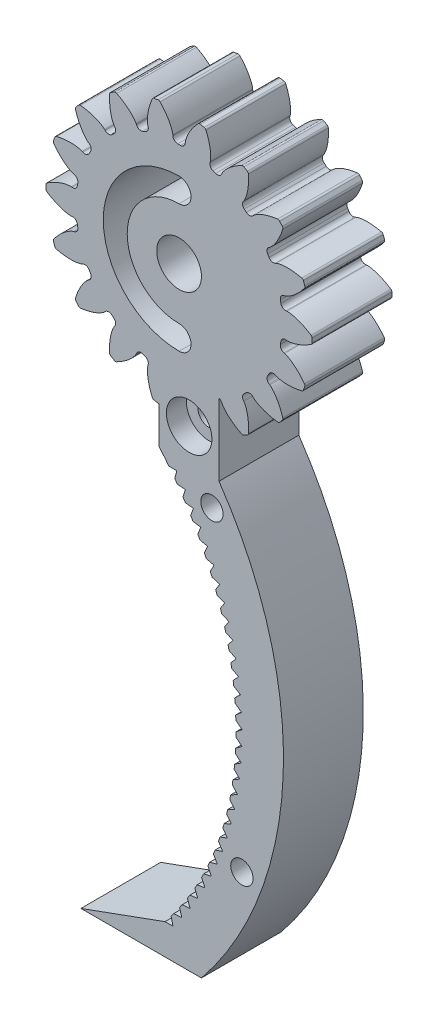
from build123d import *

# Parameters (mm, degrees)
SKETCH1_R                                 = 21.166666667
BOSS_EXTRUDE1_DEPTH                       = 12.7
CUT_EXTRUDE_DCLTBC_DEPTH                  = 13.7
FILLET_TIP_DCLTBC_R                       = 0.376401082
FILLET_ROOT_DCLTBC_R                      = 0.752802164
CIRPATTERN_DCLTBC_COUNT                   = 18
FILLET_TIP_DCLTBC_OF_CIRPATTERN_DCLTBC_R  = 0.376401082
FILLET_ROOT_DCLTBC_OF_CIRPATTERN_DCLTBC_R = 0.752802164
SKETCH4_R                                 = 3.556
CUT_EXTRUDE2_DEPTH                        = 13.7000001
BOSS_EXTRUDE3_DEPTH                       = 12.7
SKETCH9_R                                 = 1.778
CUT_EXTRUDE4_DEPTH                        = 101.6
CUT_EXTRUDE6_DEPTH                        = 13.7000001
CIRPATTERN1_COUNT                         = 30
CIRPATTERN1_ANGLE                         = 75
CUT_EXTRUDE7_DEPTH                        = 12.7
SKETCH13_R                                = 1.778
CUT_EXTRUDE8_DEPTH                        = 12.7
SKETCH14_R                                = 3.6195
CUT_EXTRUDE9_DEPTH                        = 3.175
SKETCH15_R                                = 3.6195
CUT_EXTRUDE10_DEPTH                       = 3.175


with BuildPart() as part:
    # Sketch1 → Boss-Extrude1 (new body)
    with BuildSketch(Plane.XY):
        Circle(SKETCH1_R)
    extrude(amount=BOSS_EXTRUDE1_DEPTH)

    # DCLTBC → Cut-Extrude-DCLTBC (cut, through all)
    with BuildSketch(Plane.XY):
        with BuildLine():
            Line((-0.988599485, 17.23683661), (-0.939299003, 16.37725256))
            ThreePointArc((-0.939299003, 16.37725256), (0, 16.404166667), (0.939299003, 16.37725256))
            Line((0.939299003, 16.37725256), (0.988599485, 17.23683661))
            add(Edge.make_bspline(
                [(0.988599485, 17.23683661), (0.989063314, 17.24324115), (0.990661792, 17.261181979), (0.994858273, 17.295004515), (1.003369641, 17.350013815), (1.016655031, 17.419804647), (1.036619493, 17.509601098), (1.063718234, 17.614795353), (1.097234262, 17.729707804), (1.137709634, 17.85389969), (1.181621422, 17.977005275), (1.228695452, 18.099012466), (1.278527467, 18.219794849), (1.342341331, 18.365146152), (1.42364652, 18.538069209), (1.525589195, 18.738036686), (1.649316002, 18.962165854), (1.783980218, 19.187521629), (1.923498112, 19.406676656), (2.072405817, 19.624910262), (2.222105415, 19.833784741), (2.385586794, 20.047220122), (2.540566559, 20.242458208), (2.722891612, 20.457068476), (2.872582231, 20.629074977), (3.034353491, 20.803165616), (3.114136758, 20.887359483), (3.155350355, 20.930158669)],
                knots=[0, 0, 0, 0, 0, 0.005376749, 0.015083688, 0.02853182, 0.04661014, 0.064854849, 0.092110525, 0.119476176, 0.146842496, 0.174208854, 0.201574956, 0.228941013, 0.256307345, 0.307035032, 0.361767352, 0.416499661, 0.471231937, 0.525964282, 0.580696616, 0.635428982, 0.690161387, 0.744893688, 0.799626082, 0.854358408, 0.909090915, 0.909090915, 0.909090915, 0.909090915, 0.909090915], degree=4))
            ThreePointArc((3.155350355, 20.930158669), (0, 21.166666667), (-3.155350355, 20.930158669))
            add(Edge.make_bspline(
                [(-0.988599485, 17.23683661), (-0.989063314, 17.24324115), (-0.990661792, 17.261181979), (-0.994858273, 17.295004515), (-1.003369641, 17.350013815), (-1.016655031, 17.419804647), (-1.036619493, 17.509601098), (-1.063718234, 17.614795353), (-1.097234262, 17.729707804), (-1.137709634, 17.85389969), (-1.181621422, 17.977005275), (-1.228695452, 18.099012466), (-1.278527467, 18.219794849), (-1.342341331, 18.365146152), (-1.42364652, 18.538069209), (-1.525589195, 18.738036686), (-1.649316002, 18.962165854), (-1.783980218, 19.187521629), (-1.923498112, 19.406676656), (-2.072405817, 19.624910262), (-2.222105415, 19.833784741), (-2.385586794, 20.047220122), (-2.540566559, 20.242458208), (-2.722891612, 20.457068476), (-2.872582231, 20.629074977), (-3.034353491, 20.803165616), (-3.114136758, 20.887359483), (-3.155350355, 20.930158669)],
                knots=[0, 0, 0, 0, 0, 0.005376749, 0.015083688, 0.02853182, 0.04661014, 0.064854849, 0.092110525, 0.119476176, 0.146842496, 0.174208854, 0.201574956, 0.228941013, 0.256307345, 0.307035032, 0.361767352, 0.416499661, 0.471231937, 0.525964282, 0.580696616, 0.635428982, 0.690161387, 0.744893688, 0.799626082, 0.854358408, 0.909090915, 0.909090915, 0.909090915, 0.909090915, 0.909090915], degree=4))
        make_face()
    cut_extrude_dcltbc = extrude(amount=CUT_EXTRUDE_DCLTBC_DEPTH, mode=Mode.SUBTRACT)

    # Fillet-Tip-DCLTBC
    fillet_tip_dcltbc_edges = [part.edges().sort_by_distance(p)[0] for p in [
        (3.155350355, 20.930158669, 6.35),
        (-3.155350355, 20.930158669, 6.35),
    ]]
    fillet(fillet_tip_dcltbc_edges, radius=FILLET_TIP_DCLTBC_R)

    # Fillet-Root-DCLTBC
    fillet_root_dcltbc_edges = [part.edges().sort_by_distance(p)[0] for p in [
        (0.939299003, 16.37725256, 6.35),
        (-0.939299003, 16.37725256, 6.35),
    ]]
    fillet(fillet_root_dcltbc_edges, radius=FILLET_ROOT_DCLTBC_R)

    # CirPattern-DCLTBC: Cut-Extrude-DCLTBC ×18 about axis
    cirpattern_dcltbc_axis = Axis((0, 0, 12.7), (0, 0, 1))
    for i in range(1, CIRPATTERN_DCLTBC_COUNT):
        add(cut_extrude_dcltbc.rotate(cirpattern_dcltbc_axis, i * 360 / CIRPATTERN_DCLTBC_COUNT), mode=Mode.SUBTRACT)

    # Fillet-Tip-DCLTBC of CirPattern-DCLTBC
    fillet_tip_dcltbc_of_cirpattern_dcltbc_edges = [part.edges().sort_by_distance(p)[0] for p in [
        (-4.193476424, 20.747109034, 6.35),
        (-10.123595312, 18.588722273, 6.35),
        (-11.036508056, 18.061651854, 6.35),
        (-15.870785267, 14.00521163, 6.35),
        (-16.548373935, 13.1976929, 6.35),
        (-19.70372429, 7.73246577, 6.35),
        (-20.06426169, 6.741897404, 6.35),
        (-21.160103368, 0.527070418, 6.35),
        (-21.160103368, -0.527070418, 6.35),
        (-20.06426169, -6.741897404, 6.35),
        (-19.70372429, -7.73246577, 6.35),
        (-16.548373935, -13.1976929, 6.35),
        (-15.870785267, -14.00521163, 6.35),
        (-11.036508056, -18.061651854, 6.35),
        (-10.123595312, -18.588722273, 6.35),
        (-4.193476424, -20.747109034, 6.35),
        (-3.155350355, -20.930158669, 6.35),
        (3.155350355, -20.930158669, 6.35),
        (4.193476424, -20.747109034, 6.35),
        (10.123595312, -18.588722273, 6.35),
        (11.036508056, -18.061651854, 6.35),
        (15.870785267, -14.00521163, 6.35),
        (16.548373935, -13.1976929, 6.35),
        (19.70372429, -7.73246577, 6.35),
        (20.06426169, -6.741897404, 6.35),
        (21.160103368, -0.527070418, 6.35),
        (21.160103368, 0.527070418, 6.35),
        (20.06426169, 6.741897404, 6.35),
        (19.70372429, 7.73246577, 6.35),
        (16.548373935, 13.1976929, 6.35),
        (15.870785267, 14.00521163, 6.35),
        (11.036508056, 18.061651854, 6.35),
        (10.123595312, 18.588722273, 6.35),
        (4.193476424, 20.747109034, 6.35),
    ]]
    fillet(fillet_tip_dcltbc_of_cirpattern_dcltbc_edges, radius=FILLET_TIP_DCLTBC_OF_CIRPATTERN_DCLTBC_R)

    # Fillet-Root-DCLTBC of CirPattern-DCLTBC
    fillet_root_dcltbc_of_cirpattern_dcltbc_edges = [part.edges().sort_by_distance(p)[0] for p in [
        (-4.718697926, 15.710842559, 6.35),
        (-6.48400261, 15.0683242, 6.35),
        (-9.807550244, 13.149473078, 6.35),
        (-11.246639808, 11.941933556, 6.35),
        (-13.71346726, 9.002083078, 6.35),
        (-14.652766263, 7.375169482, 6.35),
        (-15.965337734, 3.768909003, 6.35),
        (-16.291552854, 1.918851122, 6.35),
        (-16.291552854, -1.918851122, 6.35),
        (-15.965337734, -3.768909003, 6.35),
        (-14.652766263, -7.375169482, 6.35),
        (-13.71346726, -9.002083078, 6.35),
        (-11.246639808, -11.941933556, 6.35),
        (-9.807550244, -13.149473078, 6.35),
        (-6.48400261, -15.0683242, 6.35),
        (-4.718697926, -15.710842559, 6.35),
        (-0.939299003, -16.37725256, 6.35),
        (0.939299003, -16.37725256, 6.35),
        (4.718697926, -15.710842559, 6.35),
        (6.48400261, -15.0683242, 6.35),
        (9.807550244, -13.149473078, 6.35),
        (11.246639808, -11.941933556, 6.35),
        (13.71346726, -9.002083078, 6.35),
        (14.652766263, -7.375169482, 6.35),
        (15.965337734, -3.768909003, 6.35),
        (16.291552854, -1.918851122, 6.35),
        (16.291552854, 1.918851122, 6.35),
        (15.965337734, 3.768909003, 6.35),
        (14.652766263, 7.375169482, 6.35),
        (13.71346726, 9.002083078, 6.35),
        (11.246639808, 11.941933556, 6.35),
        (9.807550244, 13.149473078, 6.35),
        (6.48400261, 15.0683242, 6.35),
        (4.718697926, 15.710842559, 6.35),
    ]]
    fillet(fillet_root_dcltbc_of_cirpattern_dcltbc_edges, radius=FILLET_ROOT_DCLTBC_OF_CIRPATTERN_DCLTBC_R)

    # Sketch4 → Cut-Extrude2 (cut, through all)
    with BuildSketch(Plane.XY.offset(12.7)):
        Circle(SKETCH4_R)
    extrude(amount=-CUT_EXTRUDE2_DEPTH, mode=Mode.SUBTRACT)

    # Sketch7 → Boss-Extrude3 (add, through all)
    with BuildSketch(Plane.XY.offset(12.7)):
        with BuildLine():
            Line((6.35, -14.113720517), (6.35, -26.813720517))
            ThreePointArc((6.35, -26.813720517), (16.563553869, -62.204697552), (3.547653041, -96.663720517))
            Line((3.547653041, -96.663720517), (-15.629346959, -96.663720517))
            Line((-15.629346959, -96.663720517), (-2.2365023, -91.788432197))
            ThreePointArc((-2.2365023, -91.788432197), (9.041883703, -59.131392983), (-3.175, -26.813720517))
            Line((-3.175, -26.813720517), (-3.175, -14.113720517))
            Line((-3.175, -14.113720517), (6.35, -14.113720517))
        make_face()
    extrude(amount=-BOSS_EXTRUDE3_DEPTH)

    # Sketch9 → Cut-Extrude4 (cut)
    with BuildSketch(Plane.XY.offset(12.7)):
        with Locations((5.222816577, -31.033083261)):
            Circle(SKETCH9_R)
        with Locations((9.993601717, -78.846696124)):
            Circle(SKETCH9_R)
    extrude(amount=-CUT_EXTRUDE4_DEPTH, mode=Mode.SUBTRACT)

    # Sketch11 → Cut-Extrude6 (cut, through all)
    with BuildSketch(Plane.XY.offset(12.7)):
        with BuildLine():
            Line((-2.2365023, -91.788432197), (-0.9665023, -91.788432197))
            Line((-0.9665023, -91.788432197), (-1.271582988, -90.555620056))
            ThreePointArc((-1.271582988, -90.555620056), (-1.749293325, -91.175743408), (-2.2365023, -91.788432197))
        make_face()
    cut_extrude6 = extrude(amount=-CUT_EXTRUDE6_DEPTH, mode=Mode.SUBTRACT)

    # CirPattern1: Cut-Extrude6 ×30 about axis
    cirpattern1_axis = Axis((-41.752817912, -59.865073971, 0), (0, 0, 1))
    for i in range(1, CIRPATTERN1_COUNT):
        add(cut_extrude6.rotate(cirpattern1_axis, i * CIRPATTERN1_ANGLE / (CIRPATTERN1_COUNT - 1)), mode=Mode.SUBTRACT)

    # Sketch12 → Cut-Extrude7 (cut)
    with BuildSketch(Plane.XY.offset(12.7)):
        with BuildLine():
            ThreePointArc((0, 12.065), (-12.065, 0), (0, -12.065))
            ThreePointArc((0, -12.065), (1.905, -10.16), (0, -8.255))
            ThreePointArc((0, -8.255), (-8.255, 0), (0, 8.255))
            ThreePointArc((0, 8.255), (1.905, 10.16), (0, 12.065))
        make_face()
    extrude(amount=-CUT_EXTRUDE7_DEPTH, mode=Mode.SUBTRACT)

    # Sketch13 → Cut-Extrude8 (cut)
    with BuildSketch(Plane.XY.offset(12.7)):
        with Locations((1.6002, -21.59)):
            Circle(SKETCH13_R)
    extrude(amount=-CUT_EXTRUDE8_DEPTH, mode=Mode.SUBTRACT)

    # Sketch14 → Cut-Extrude9 (cut)
    with BuildSketch(Plane.XY.offset(12.7)):
        with Locations((1.6002, -21.59)):
            Circle(SKETCH14_R)
    extrude(amount=-CUT_EXTRUDE9_DEPTH, mode=Mode.SUBTRACT)

    # Sketch15 → Cut-Extrude10 (cut)
    with BuildSketch(Plane(origin=(0, 0, 0), x_dir=(-1, 0, 0), z_dir=(0, 0, -1))):
        with Locations((-1.6002, -21.59)):
            Circle(SKETCH15_R)
    extrude(amount=-CUT_EXTRUDE10_DEPTH, mode=Mode.SUBTRACT)


solid = part.part
